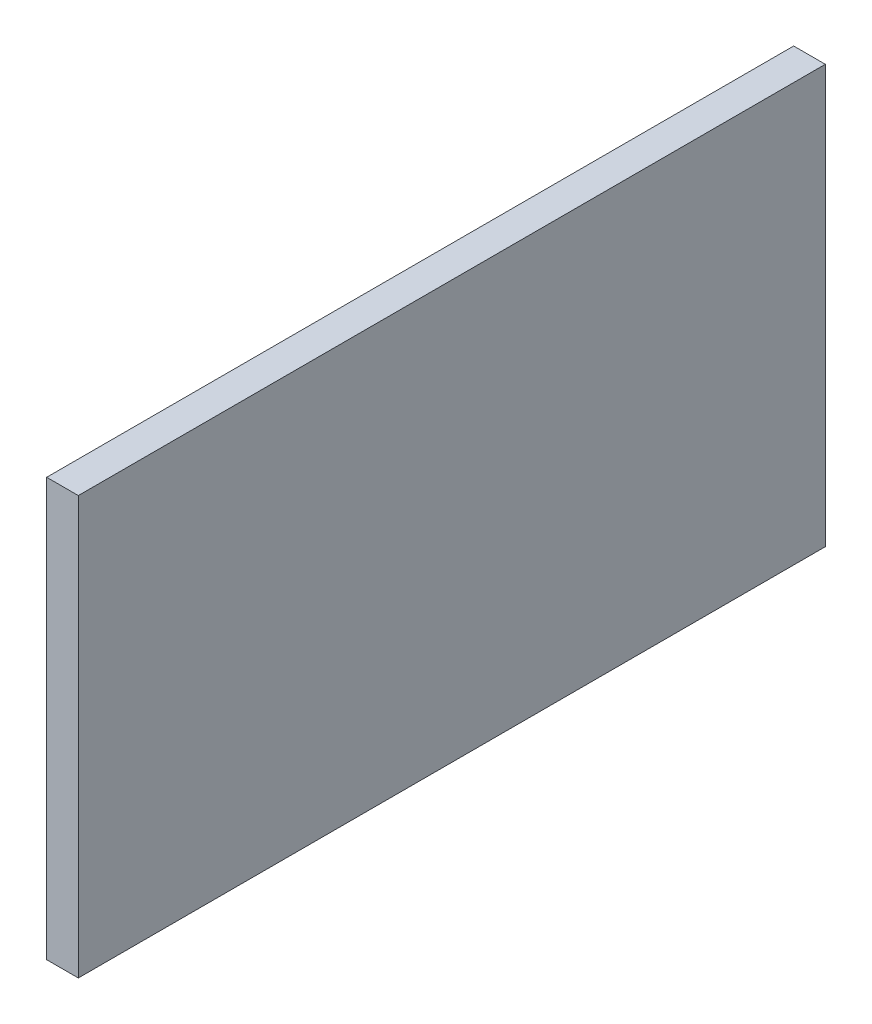
from build123d import *

# Parameters (mm, degrees)
SKETCH1_W           = 74.93
SKETCH1_H           = 41.91
BOSS_EXTRUDE1_DEPTH = 3.175


with BuildPart() as part:
    # Sketch1 → Boss-Extrude1 (new body)
    with BuildSketch(Plane(origin=(0, 0, 0), x_dir=(0, 0, -1), z_dir=(1, 0, 0))):
        Rectangle(SKETCH1_W, SKETCH1_H)
    extrude(amount=BOSS_EXTRUDE1_DEPTH)


solid = part.part
